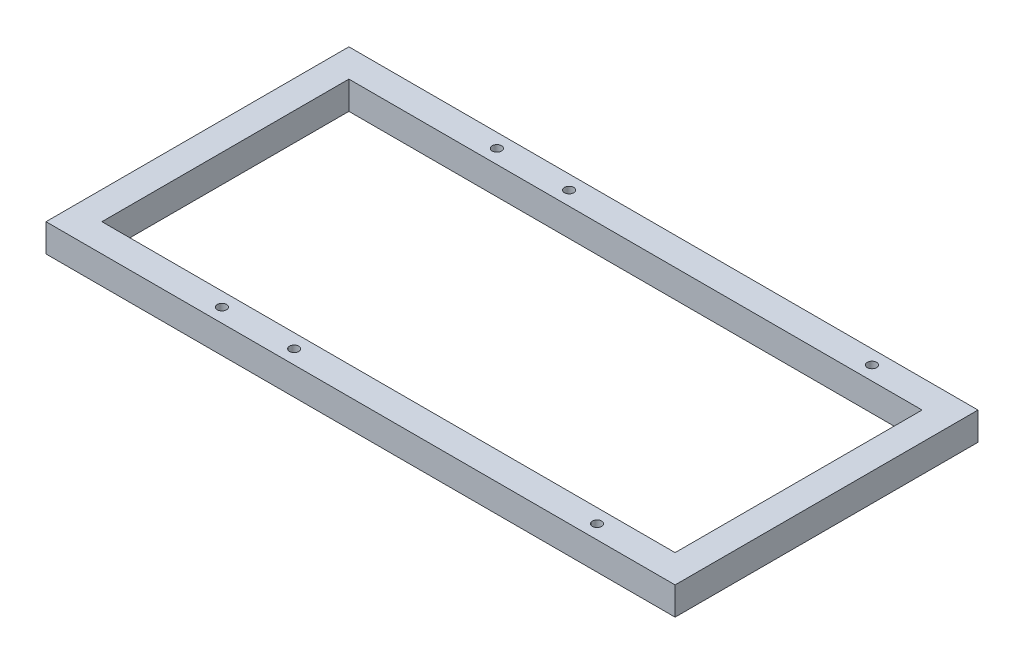
from build123d import *

# Parameters (mm, degrees)
SKETCH1_W                 = 270
SKETCH1_H                 = 130
SKETCH1_W_2               = 246
SKETCH1_H_2               = 106
BOSS_EXTRUDE1_DEPTH       = 12
SKETCH3_R                 = 2
CUT_EXTRUDE1_DEPTH        = 50.25
LPATTERN1_COUNT           = 2
LPATTERN1_PITCH           = 31
LPATTERN1_COPY_1_SKETCH_R = 2
LPATTERN1_COPY_1_DEPTH    = 50.25
LPATTERN2_COUNT           = 2
LPATTERN2_PITCH           = 161
MIRROR2_COPY_1_SKETCH_R   = 2
MIRROR2_COPY_1_DEPTH      = 50.25
MIRROR2_COPY_2_SKETCH_R   = 2
MIRROR2_COPY_2_DEPTH      = 50.25


with BuildPart() as part:
    # Sketch1 → Boss-Extrude1 (new body)
    with BuildSketch(Plane(origin=(0, 0, 0), x_dir=(1, 0, 0), z_dir=(0, 1, 0))):
        Rectangle(SKETCH1_W, SKETCH1_H)
        Rectangle(SKETCH1_W_2, SKETCH1_H_2, mode=Mode.SUBTRACT)
    extrude(amount=BOSS_EXTRUDE1_DEPTH)

    # Sketch3 → Cut-Extrude1 (cut)
    with BuildSketch(Plane(origin=(0, 12, 0), x_dir=(1, 0, 0), z_dir=(0, 1, 0))):
        with Locations((-65.5, -59)):
            Circle(SKETCH3_R)
    cut_extrude1 = extrude(amount=-CUT_EXTRUDE1_DEPTH, mode=Mode.SUBTRACT)

    # Mirror1: Cut-Extrude1 across plane
    add(cut_extrude1.mirror(Plane.XY), mode=Mode.SUBTRACT)

    # LPattern1: Cut-Extrude1 ×2
    with Locations(*[(i * LPATTERN1_PITCH, 0, 0) for i in range(1, LPATTERN1_COUNT)]):
        add(cut_extrude1, mode=Mode.SUBTRACT)

    # LPattern1 copy 1 sketch → LPattern1 copy 1 (cut)
    with BuildSketch(Plane(origin=(31, 12, 0), x_dir=(1, 0, 0), z_dir=(0, 1, 0))):
        with Locations((-65.5, 59)):
            Circle(LPATTERN1_COPY_1_SKETCH_R)
    extrude(amount=-LPATTERN1_COPY_1_DEPTH, mode=Mode.SUBTRACT)

    # LPattern2: Cut-Extrude1 ×2
    with Locations(*[(i * LPATTERN2_PITCH, 0, 0) for i in range(1, LPATTERN2_COUNT)]):
        add(cut_extrude1, mode=Mode.SUBTRACT)

    # Mirror2 copy 1 sketch → Mirror2 copy 1 (cut)
    with BuildSketch(Plane(origin=(161, 12, 0), x_dir=(1, 0, 0), z_dir=(0, 1, 0))):
        with Locations((-65.5, 59)):
            Circle(MIRROR2_COPY_1_SKETCH_R)
    extrude(amount=-MIRROR2_COPY_1_DEPTH, mode=Mode.SUBTRACT)

    # Mirror2 copy 2 sketch → Mirror2 copy 2 (cut)
    with BuildSketch(Plane(origin=(0, 12, 0), x_dir=(1, 0, 0), z_dir=(0, 1, 0))):
        with Locations((-65.5, 59)):
            Circle(MIRROR2_COPY_2_SKETCH_R)
    extrude(amount=-MIRROR2_COPY_2_DEPTH, mode=Mode.SUBTRACT)


solid = part.part
